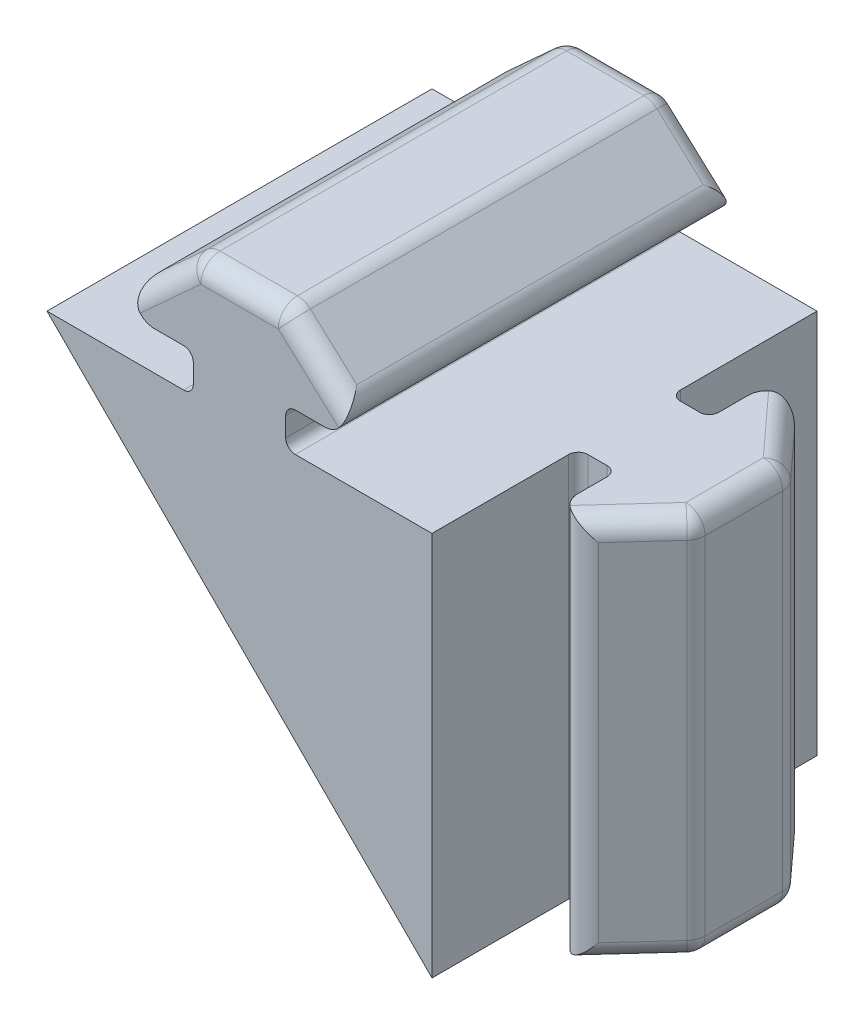
from build123d import *

# Parameters (mm, degrees)
BOSS_EXTRUDE1_DEPTH = 20
BOSS_EXTRUDE2_DEPTH = 20
FILLET3_R           = 1
FILLET4_R           = 0.5


with BuildPart() as part:
    # Sketch1 → Boss-Extrude1 (new body)
    with BuildSketch(Plane.XY):
        Polygon((7.6, 26.2), (12.4, 26.2), (17, 22), (12.4, 22), (12.4, 20), (20, 20), (20, 0), (0, 0), (0, 20), (7.6, 20), (7.6, 22), (3, 22), align=None)
    extrude(amount=-BOSS_EXTRUDE1_DEPTH)

    # Sketch2 → Boss-Extrude2 (add)
    with BuildSketch(Plane(origin=(0, 0, 0), x_dir=(0, 0, -1), z_dir=(0, -1, 0))):
        Polygon((7.6, 26.2), (12.4, 26.2), (17, 22), (12.4, 22), (12.4, 20), (20, 20), (20, 0), (0, 0), (0, 20), (7.6, 20), (7.6, 22), (3, 22), align=None)
    extrude(amount=-BOSS_EXTRUDE2_DEPTH)

    # SurfaceCut1
    split(bisect_by=Plane(origin=(10, 10, 0), x_dir=(0.7071067811865476, -0.7071067811865475, 0), z_dir=(0.7071067811865475, 0.7071067811865476, 0)), keep=Keep.TOP)

    # Fillet3
    fillet3_edges = [part.edges().sort_by_distance(p)[0] for p in [
        (5.3, 24.1, -20),
        (5.3, 24.1, 0),
        (10, 26.2, 0),
        (14.7, 24.1, 0),
        (17, 22, -10),
        (3, 22, -10),
        (7.6, 26.2, -10),
        (12.4, 26.2, -10),
        (24.1, 20, -14.7),
        (26.2, 10, -12.4),
        (22, 10, -17),
        (14.7, 24.1, -20),
        (24.1, 20, -5.3),
        (22, 10, -3),
        (26.2, 20, -10),
        (26.2, 10, -7.6),
        (24.1, 0, -14.7),
        (26.2, 0, -10),
        (24.1, 0, -5.3),
        (10, 26.2, -20),
    ]]
    fillet(fillet3_edges, radius=FILLET3_R)

    # Fillet4
    fillet4_edges = [part.edges().sort_by_distance(p)[0] for p in [
        (12.4, 22, -10),
        (12.4, 20, -10),
        (7.6, 20, -10),
        (7.6, 22, -10),
        (22, 10, -12.4),
        (20, 10, -12.4),
        (20, 10, -7.6),
        (22, 10, -7.6),
    ]]
    fillet(fillet4_edges, radius=FILLET4_R)


solid = part.part
